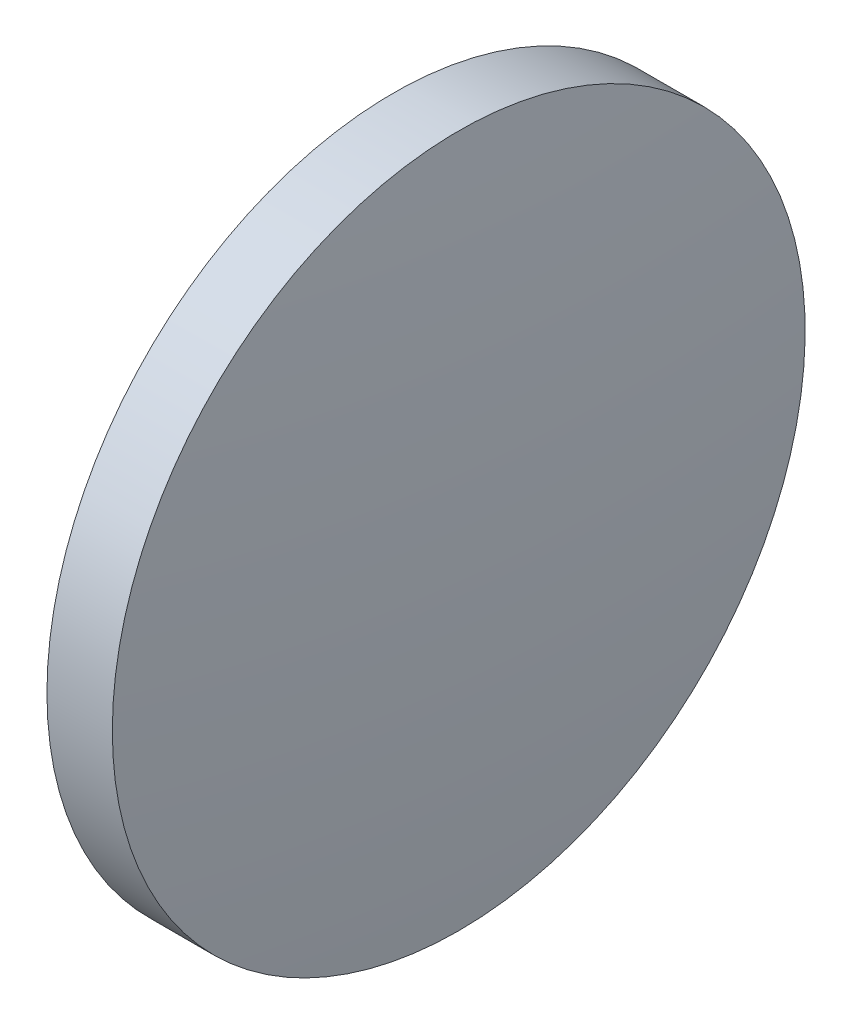
from build123d import *


with BuildPart() as part:
    # 草图1 → 旋转1 (revolve)
    with BuildSketch(Plane.XY, mode=Mode.PRIVATE) as revolve_1_sk:
        with BuildLine():
            Line((679.000854272, 360.850810461), (679.000854272, 368.850810461))
            Line((679.000854272, 368.850810461), (680.510854272, 368.850810461))
            ThreePointArc((680.510854272, 368.850810461), (680.803296412, 364.855560766), (680.900854272, 360.850810461))
            Line((680.900854272, 360.850810461), (679.000854272, 360.850810461))
        make_face()
    revolve(revolve_1_sk.sketch.rotate(Axis((675.275585652, 360.850810461, 0), (1, 0, 0)), 180), axis=Axis((675.275585652, 360.850810461, 0), (1, 0, 0)))  # turned: the seam where the file's is


solid = part.part
